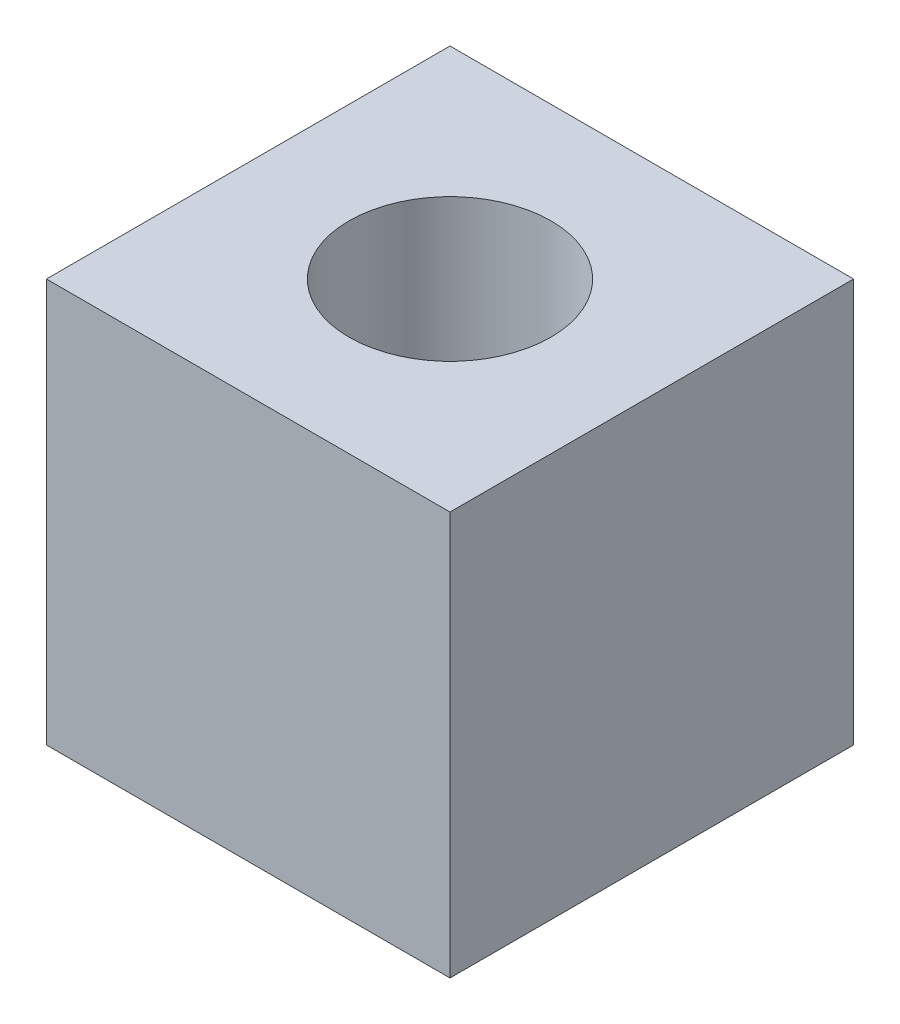
from build123d import *

# Parameters (mm, degrees)
SKETCH1_W           = 50.8
SKETCH1_H           = 50.8
BOSS_EXTRUDE1_DEPTH = 50.8
CUT_EXTRUDE1_REACH  = 52.8
SKETCH2_R           = 12.7


with BuildPart() as part:
    # Sketch1 → Boss-Extrude1 (new body)
    with BuildSketch(Plane.XY):
        with Locations((25.4, -25.4)):
            Rectangle(SKETCH1_W, SKETCH1_H)
    extrude(amount=BOSS_EXTRUDE1_DEPTH)

    # Sketch2 → Cut-Extrude1 (cut, up to next)
    with BuildSketch(Plane(origin=(0, 0, 0), x_dir=(1, 0, 0), z_dir=(0, 1, 0)), mode=Mode.PRIVATE) as cut_extrude1_sk1:
        with Locations((25.4, -25.4)):
            Circle(SKETCH2_R)
    cut_extrude1_tool1 = extrude(cut_extrude1_sk1.sketch, amount=-CUT_EXTRUDE1_REACH, mode=Mode.PRIVATE) & part.part
    add(cut_extrude1_tool1.solids().sort_by_distance((25.4, 0, 25.4))[0], mode=Mode.SUBTRACT)


solid = part.part
